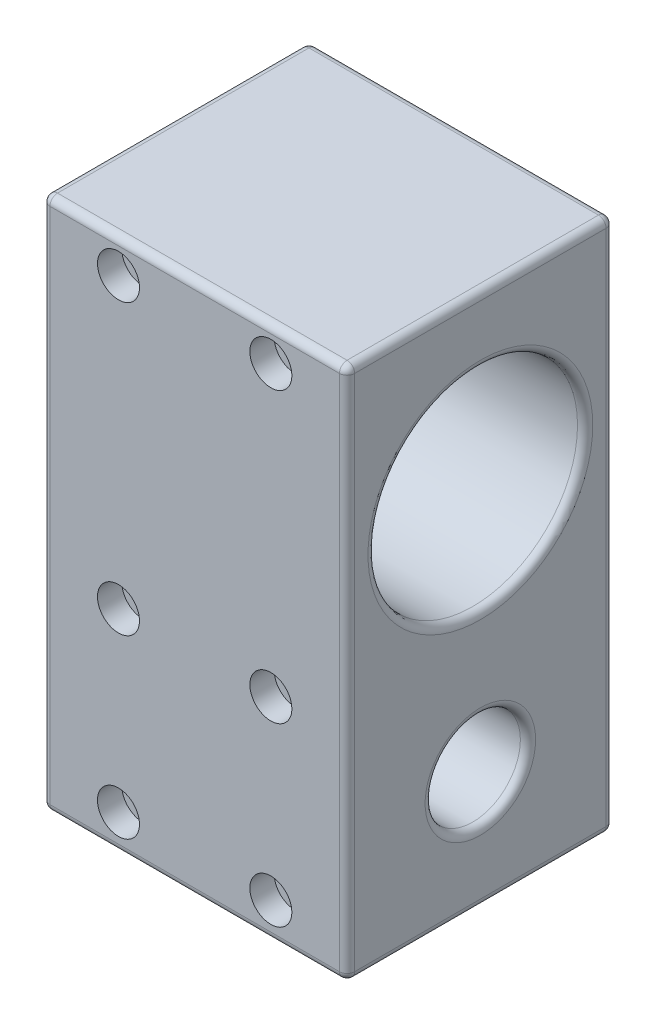
from build123d import *

# Parameters (mm, degrees)
SKETCH1_W           = 44.45
SKETCH1_H           = 88.9
SKETCH1_R           = 7.9375
SKETCH1_R_2         = 17.4625
BOSS_EXTRUDE1_DEPTH = 50.8
SKETCH5_R           = 2.032
CUT_EXTRUDE1_DEPTH  = 112.622813528
SKETCH5_3_R         = 3.5
CUT_EXTRUDE2_DEPTH  = 4.064
CUT_EXTRUDE3_START  = -2.54
SKETCH6_R           = 2.032
CUT_EXTRUDE3_DEPTH  = 2.54
FILLET1_R           = 1.27


with BuildPart() as part:
    # Sketch1 → Boss-Extrude1 (new body)
    with BuildSketch(Plane(origin=(0, 0, 0), x_dir=(0, 0, -1), z_dir=(1, 0, 0))):
        with Locations((22.225, 44.45)):
            Rectangle(SKETCH1_W, SKETCH1_H)
        with Locations((22.225, 19.685)):
            Circle(SKETCH1_R, mode=Mode.SUBTRACT)
        with Locations((22.225, 60.325)):
            Circle(SKETCH1_R_2, mode=Mode.SUBTRACT)
    extrude(amount=BOSS_EXTRUDE1_DEPTH)

    # Sketch5 → Cut-Extrude1 (cut, through all)
    with BuildSketch(Plane.XY):
        with Locations((38.1, 35.2425)):
            Circle(SKETCH5_R)
        with Locations((12.7, 83.34375)):
            Circle(SKETCH5_R)
        with Locations((38.1, 83.34375)):
            Circle(SKETCH5_R)
        with Locations((12.7, 35.2425)):
            Circle(SKETCH5_R)
        with Locations((38.1, 5.87375)):
            Circle(SKETCH5_R)
        with Locations((12.7, 5.87375)):
            Circle(SKETCH5_R)
    extrude(amount=-CUT_EXTRUDE1_DEPTH, mode=Mode.SUBTRACT)

    # Sketch5_3 → Cut-Extrude2 (cut)
    with BuildSketch(Plane.XY):
        with Locations((38.1, 35.2425)):
            Circle(SKETCH5_3_R)
        with Locations((12.7, 83.34375)):
            Circle(SKETCH5_3_R)
        with Locations((38.1, 83.34375)):
            Circle(SKETCH5_3_R)
        with Locations((12.7, 35.2425)):
            Circle(SKETCH5_3_R)
        with Locations((38.1, 5.87375)):
            Circle(SKETCH5_3_R)
        with Locations((12.7, 5.87375)):
            Circle(SKETCH5_3_R)
    extrude(amount=-CUT_EXTRUDE2_DEPTH, mode=Mode.SUBTRACT)

    # Sketch6 → Cut-Extrude3 (cut)
    # profile 1 of 6: a face of its own
    with BuildSketch(Plane(origin=(0, 0, -44.45), x_dir=(-1, 0, 0), z_dir=(0, 0, -1)).offset(CUT_EXTRUDE3_START)):
        Polygon((-10.668, 79.824222759), (-8.636, 83.34375), (-10.668, 86.863277241), (-14.732, 86.863277241), (-16.764, 83.34375), (-14.732, 79.824222759), align=None)
    # profile 2 of 6: a face of its own
    with BuildSketch(Plane(origin=(0, 0, -44.45), x_dir=(-1, 0, 0), z_dir=(0, 0, -1)).offset(CUT_EXTRUDE3_START)):
        Polygon((-36.068, 79.824222759), (-34.036, 83.34375), (-36.068, 86.863277241), (-40.132, 86.863277241), (-42.164, 83.34375), (-40.132, 79.824222759), align=None)
        with Locations((-38.1, 83.34375)):
            Circle(SKETCH6_R, mode=Mode.SUBTRACT)
    # profile 3 of 6: a face of its own
    with BuildSketch(Plane(origin=(0, 0, -44.45), x_dir=(-1, 0, 0), z_dir=(0, 0, -1)).offset(CUT_EXTRUDE3_START)):
        Polygon((-36.068, 31.722972759), (-34.036, 35.2425), (-36.068, 38.762027241), (-40.132, 38.762027241), (-42.164, 35.2425), (-40.132, 31.722972759), align=None)
        with Locations((-38.1, 35.2425)):
            Circle(SKETCH6_R, mode=Mode.SUBTRACT)
    # profile 4 of 6: a face of its own
    with BuildSketch(Plane(origin=(0, 0, -44.45), x_dir=(-1, 0, 0), z_dir=(0, 0, -1)).offset(CUT_EXTRUDE3_START)):
        Polygon((-10.668, 31.722972759), (-8.636, 35.2425), (-10.668, 38.762027241), (-14.732, 38.762027241), (-16.764, 35.2425), (-14.732, 31.722972759), align=None)
        with Locations((-12.7, 35.2425)):
            Circle(SKETCH6_R, mode=Mode.SUBTRACT)
    # profile 5 of 6: a face of its own
    with BuildSketch(Plane(origin=(0, 0, -44.45), x_dir=(-1, 0, 0), z_dir=(0, 0, -1)).offset(CUT_EXTRUDE3_START)):
        Polygon((-10.668, 2.354222759), (-8.636, 5.87375), (-10.668, 9.393277241), (-14.732, 9.393277241), (-16.764, 5.87375), (-14.732, 2.354222759), align=None)
        with Locations((-12.7, 5.87375)):
            Circle(SKETCH6_R, mode=Mode.SUBTRACT)
    # profile 6 of 6: a face of its own
    with BuildSketch(Plane(origin=(0, 0, -44.45), x_dir=(-1, 0, 0), z_dir=(0, 0, -1)).offset(CUT_EXTRUDE3_START)):
        Polygon((-36.068, 2.354222759), (-34.036, 5.87375), (-36.068, 9.393277241), (-40.132, 9.393277241), (-42.164, 5.87375), (-40.132, 2.354222759), align=None)
        with Locations((-38.1, 5.87375)):
            Circle(SKETCH6_R, mode=Mode.SUBTRACT)
    extrude(amount=CUT_EXTRUDE3_DEPTH, mode=Mode.SUBTRACT)

    # Fillet1
    fillet1_edges = [part.edges().sort_by_distance(p)[0] for p in [
        (25.4, 0, 0),
        (25.4, 0, -44.45),
        (0, 19.685, -14.2875),
        (0, 0, -22.225),
        (50.8, 19.685, -14.2875),
        (50.8, 0, -22.225),
        (50.8, 60.325, -4.7625),
        (50.8, 44.45, 0),
        (50.8, 44.45, -44.45),
        (0, 60.325, -4.7625),
        (0, 44.45, 0),
        (0, 44.45, -44.45),
        (25.4, 88.9, 0),
        (0, 88.9, -22.225),
        (50.8, 88.9, -22.225),
        (25.4, 88.9, -44.45),
    ]]
    fillet(fillet1_edges, radius=FILLET1_R)


solid = part.part
